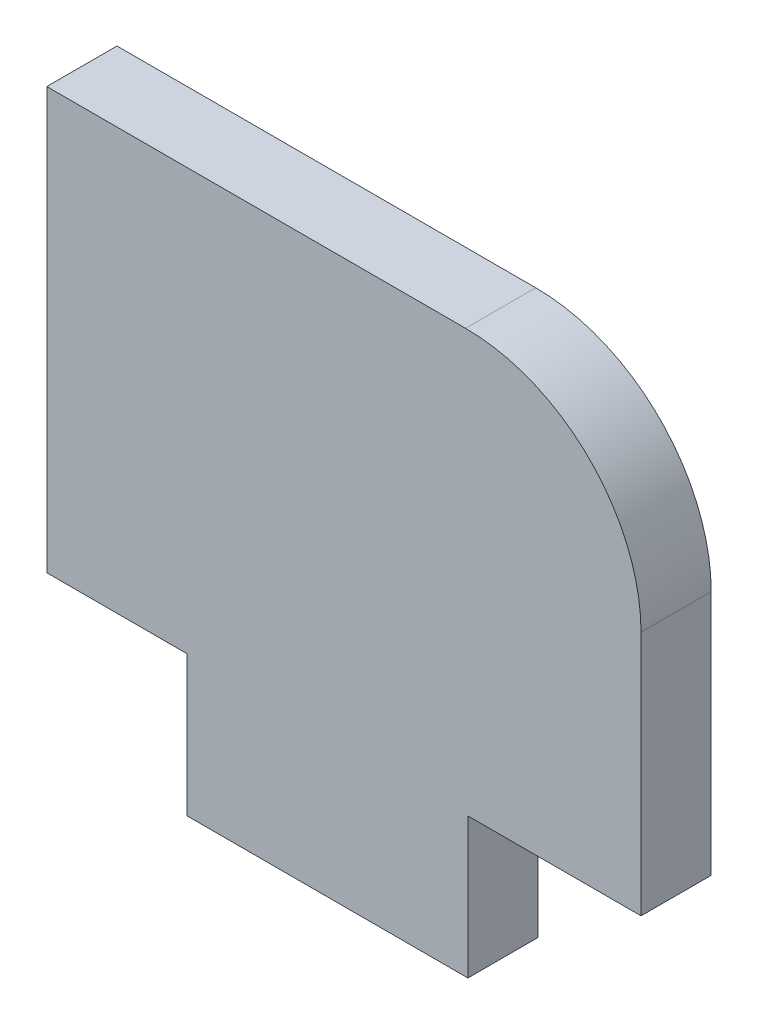
from build123d import *

# Parameters (mm, degrees)
BOSS_EXTRUDE1_DEPTH = 2


with BuildPart() as part:
    # Sketch1 → Boss-Extrude1 (new body)
    with BuildSketch(Plane.XY):
        with BuildLine():
            Line((5.533412898, -4), (10.466587102, -4))
            Line((10.466587102, -4), (10.466587102, 3))
            ThreePointArc((10.466587102, 3), (9.002121008, 6.535533906), (5.466587102, 8))
            Line((5.466587102, 8), (-6.466587102, 8))
            Line((-6.466587102, 8), (-6.466587102, -4))
            Line((-6.466587102, -4), (-2.466587102, -4))
            Line((-2.466587102, -4), (-2.466587102, -8))
            Line((-2.466587102, -8), (5.533412898, -8))
            Line((5.533412898, -8), (5.533412898, -4))
        make_face()
    extrude(amount=BOSS_EXTRUDE1_DEPTH)


solid = part.part
